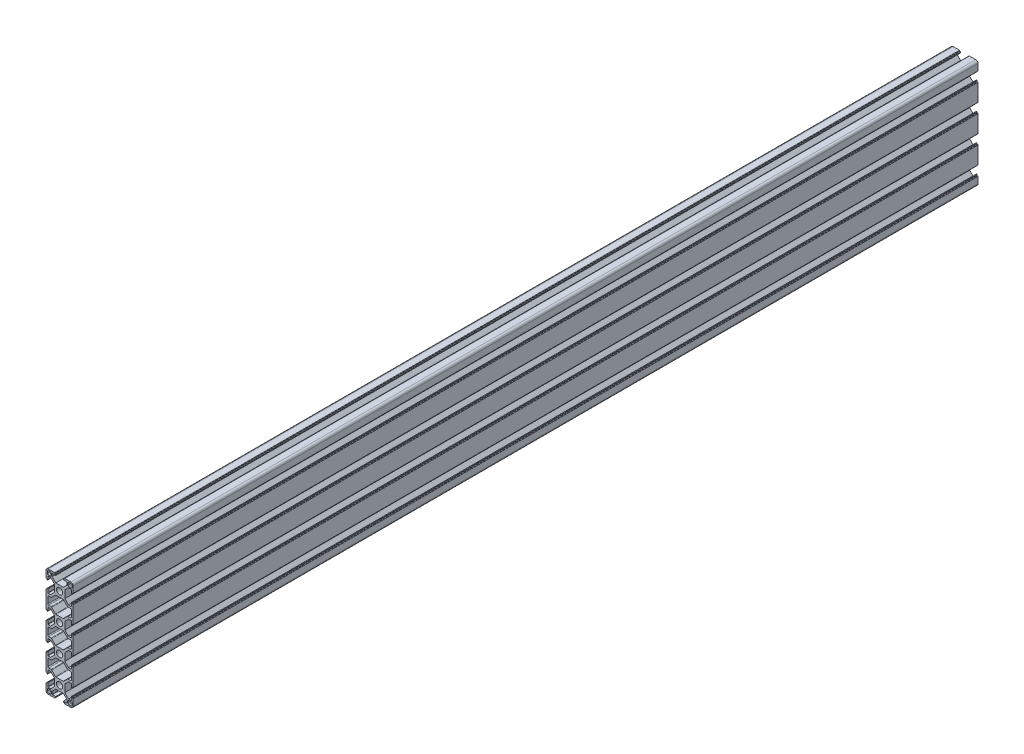
from build123d import *

# Parameters (mm, degrees)
SKETCH_1_R      = 3.4
EXTRUDE_1_DEPTH = 1000


with BuildPart() as part:
    # Эскиз1 → Бобышка-Вытянуть1 (new body)
    with BuildSketch(Plane.XY):
        with BuildLine():
            Line((-15, 8.25), (-15, 12.5))
            ThreePointArc((-15, 12.5), (-14.267766953, 14.267766953), (-12.5, 15))
            Line((-12.5, 15), (-8.25, 15))
            Line((-8.25, 15), (-5.5, 15))
            ThreePointArc((-5.5, 15), (-5.287867966, 14.912132034), (-5.2, 14.7))
            Line((-5.2, 14.7), (-5.2, 14.3))
            ThreePointArc((-5.2, 14.3), (-5.112132034, 14.087867966), (-4.9, 14))
            Line((-4.9, 14), (-4.4, 14))
            ThreePointArc((-4.4, 14), (-4.187867966, 13.912132034), (-4.1, 13.7))
            Line((-4.1, 13.7), (-4.1, 13.3))
            ThreePointArc((-4.1, 13.3), (-4.187867966, 13.087867966), (-4.4, 13))
            Line((-4.4, 13), (-7.95, 13))
            ThreePointArc((-7.95, 13), (-8.162132034, 12.912132034), (-8.25, 12.7))
            Line((-8.25, 12.7), (-8.25, 9.85))
            Line((-8.25, 9.85), (-4.2, 5.8))
            Line((-4.2, 5.8), (4.2, 5.8))
            Line((4.2, 5.8), (8.25, 9.85))
            Line((8.25, 9.85), (8.25, 12.7))
            ThreePointArc((8.25, 12.7), (8.162132034, 12.912132034), (7.95, 13))
            Line((7.95, 13), (4.4, 13))
            ThreePointArc((4.4, 13), (4.187867966, 13.087867966), (4.1, 13.3))
            Line((4.1, 13.3), (4.1, 13.7))
            ThreePointArc((4.1, 13.7), (4.187867966, 13.912132034), (4.4, 14))
            Line((4.4, 14), (4.9, 14))
            ThreePointArc((4.9, 14), (5.112132034, 14.087867966), (5.2, 14.3))
            Line((5.2, 14.3), (5.2, 14.7))
            ThreePointArc((5.2, 14.7), (5.287867966, 14.912132034), (5.5, 15))
            Line((5.5, 15), (8.25, 15))
            Line((8.25, 15), (12.5, 15))
            ThreePointArc((12.5, 15), (14.267766953, 14.267766953), (15, 12.5))
            Line((15, 12.5), (15, 8.25))
            Line((15, 8.25), (15, 5.5))
            ThreePointArc((15, 5.5), (14.912132034, 5.287867966), (14.7, 5.2))
            Line((14.7, 5.2), (14.3, 5.2))
            ThreePointArc((14.3, 5.2), (14.087867966, 5.112132034), (14, 4.9))
            Line((14, 4.9), (14, 4.4))
            ThreePointArc((14, 4.4), (13.912132034, 4.187867966), (13.7, 4.1))
            Line((13.7, 4.1), (13.3, 4.1))
            ThreePointArc((13.3, 4.1), (13.087867966, 4.187867966), (13, 4.4))
            Line((13, 4.4), (13, 7.95))
            ThreePointArc((13, 7.95), (12.912132034, 8.162132034), (12.7, 8.25))
            Line((12.7, 8.25), (9.85, 8.25))
            Line((9.85, 8.25), (5.8, 4.2))
            Line((5.8, 4.2), (5.8, -4.2))
            Line((5.8, -4.2), (9.85, -8.25))
            Line((9.85, -8.25), (12.7, -8.25))
            ThreePointArc((12.7, -8.25), (12.912132034, -8.162132034), (13, -7.95))
            Line((13, -7.95), (13, -4.4))
            ThreePointArc((13, -4.4), (13.087867966, -4.187867966), (13.3, -4.1))
            Line((13.3, -4.1), (13.7, -4.1))
            ThreePointArc((13.7, -4.1), (13.912132034, -4.187867966), (14, -4.4))
            Line((14, -4.4), (14, -4.9))
            ThreePointArc((14, -4.9), (14.087867966, -5.112132034), (14.3, -5.2))
            Line((14.3, -5.2), (14.7, -5.2))
            ThreePointArc((14.7, -5.2), (14.912132034, -5.287867966), (15, -5.5))
            Line((15, -5.5), (15, -8.25))
            Line((15, -8.25), (15, -21.75))
            Line((15, -21.75), (15, -24.5))
            ThreePointArc((15, -24.5), (14.912132034, -24.712132034), (14.7, -24.8))
            Line((14.7, -24.8), (14.3, -24.8))
            ThreePointArc((14.3, -24.8), (14.087867966, -24.887867966), (14, -25.1))
            Line((14, -25.1), (14, -25.6))
            ThreePointArc((14, -25.6), (13.912132034, -25.812132034), (13.7, -25.9))
            Line((13.7, -25.9), (13.3, -25.9))
            ThreePointArc((13.3, -25.9), (13.087867966, -25.812132034), (13, -25.6))
            Line((13, -25.6), (13, -22.05))
            ThreePointArc((13, -22.05), (12.912132034, -21.837867966), (12.7, -21.75))
            Line((12.7, -21.75), (9.85, -21.75))
            Line((9.85, -21.75), (5.8, -25.8))
            Line((5.8, -25.8), (5.8, -34.2))
            Line((5.8, -34.2), (9.85, -38.25))
            Line((9.85, -38.25), (12.7, -38.25))
            ThreePointArc((12.7, -38.25), (12.912132034, -38.162132034), (13, -37.95))
            Line((13, -37.95), (13, -34.4))
            ThreePointArc((13, -34.4), (13.087867966, -34.187867966), (13.3, -34.1))
            Line((13.3, -34.1), (13.7, -34.1))
            ThreePointArc((13.7, -34.1), (13.912132034, -34.187867966), (14, -34.4))
            Line((14, -34.4), (14, -34.9))
            ThreePointArc((14, -34.9), (14.087867966, -35.112132034), (14.3, -35.2))
            Line((14.3, -35.2), (14.7, -35.2))
            ThreePointArc((14.7, -35.2), (14.912132034, -35.287867966), (15, -35.5))
            Line((15, -35.5), (15, -38.25))
            Line((15, -38.25), (15, -51.75))
            Line((15, -51.75), (15, -54.5))
            ThreePointArc((15, -54.5), (14.912132034, -54.712132034), (14.7, -54.8))
            Line((14.7, -54.8), (14.3, -54.8))
            ThreePointArc((14.3, -54.8), (14.087867966, -54.887867966), (14, -55.1))
            Line((14, -55.1), (14, -55.6))
            ThreePointArc((14, -55.6), (13.912132034, -55.812132034), (13.7, -55.9))
            Line((13.7, -55.9), (13.3, -55.9))
            ThreePointArc((13.3, -55.9), (13.087867966, -55.812132034), (13, -55.6))
            Line((13, -55.6), (13, -52.05))
            ThreePointArc((13, -52.05), (12.912132034, -51.837867966), (12.7, -51.75))
            Line((12.7, -51.75), (9.85, -51.75))
            Line((9.85, -51.75), (5.8, -55.8))
            Line((5.8, -55.8), (5.8, -64.2))
            Line((5.8, -64.2), (9.85, -68.25))
            Line((9.85, -68.25), (12.7, -68.25))
            ThreePointArc((12.7, -68.25), (12.912132034, -68.162132034), (13, -67.95))
            Line((13, -67.95), (13, -64.4))
            ThreePointArc((13, -64.4), (13.087867966, -64.187867966), (13.3, -64.1))
            Line((13.3, -64.1), (13.7, -64.1))
            ThreePointArc((13.7, -64.1), (13.912132034, -64.187867966), (14, -64.4))
            Line((14, -64.4), (14, -64.9))
            ThreePointArc((14, -64.9), (14.087867966, -65.112132034), (14.3, -65.2))
            Line((14.3, -65.2), (14.7, -65.2))
            ThreePointArc((14.7, -65.2), (14.912132034, -65.287867966), (15, -65.5))
            Line((15, -65.5), (15, -68.25))
            Line((15, -68.25), (15, -81.75))
            Line((15, -81.75), (15, -84.5))
            ThreePointArc((15, -84.5), (14.912132034, -84.712132034), (14.7, -84.8))
            Line((14.7, -84.8), (14.3, -84.8))
            ThreePointArc((14.3, -84.8), (14.087867966, -84.887867966), (14, -85.1))
            Line((14, -85.1), (14, -85.6))
            ThreePointArc((14, -85.6), (13.912132034, -85.812132034), (13.7, -85.9))
            Line((13.7, -85.9), (13.3, -85.9))
            ThreePointArc((13.3, -85.9), (13.087867966, -85.812132034), (13, -85.6))
            Line((13, -85.6), (13, -82.05))
            ThreePointArc((13, -82.05), (12.912132034, -81.837867966), (12.7, -81.75))
            Line((12.7, -81.75), (9.85, -81.75))
            Line((9.85, -81.75), (5.8, -85.8))
            Line((5.8, -85.8), (5.8, -94.2))
            Line((5.8, -94.2), (9.85, -98.25))
            Line((9.85, -98.25), (12.7, -98.25))
            ThreePointArc((12.7, -98.25), (12.912132034, -98.162132034), (13, -97.95))
            Line((13, -97.95), (13, -94.4))
            ThreePointArc((13, -94.4), (13.087867966, -94.187867966), (13.3, -94.1))
            Line((13.3, -94.1), (13.7, -94.1))
            ThreePointArc((13.7, -94.1), (13.912132034, -94.187867966), (14, -94.4))
            Line((14, -94.4), (14, -94.9))
            ThreePointArc((14, -94.9), (14.087867966, -95.112132034), (14.3, -95.2))
            Line((14.3, -95.2), (14.7, -95.2))
            ThreePointArc((14.7, -95.2), (14.912132034, -95.287867966), (15, -95.5))
            Line((15, -95.5), (15, -98.25))
            Line((15, -98.25), (15, -102.5))
            ThreePointArc((15, -102.5), (14.267766953, -104.267766953), (12.5, -105))
            Line((12.5, -105), (8.25, -105))
            Line((8.25, -105), (5.5, -105))
            ThreePointArc((5.5, -105), (5.287867966, -104.912132034), (5.2, -104.7))
            Line((5.2, -104.7), (5.2, -104.3))
            ThreePointArc((5.2, -104.3), (5.112132034, -104.087867966), (4.9, -104))
            Line((4.9, -104), (4.4, -104))
            ThreePointArc((4.4, -104), (4.187867966, -103.912132034), (4.1, -103.7))
            Line((4.1, -103.7), (4.1, -103.3))
            ThreePointArc((4.1, -103.3), (4.187867966, -103.087867966), (4.4, -103))
            Line((4.4, -103), (7.95, -103))
            ThreePointArc((7.95, -103), (8.162132034, -102.912132034), (8.25, -102.7))
            Line((8.25, -102.7), (8.25, -99.85))
            Line((8.25, -99.85), (4.2, -95.8))
            Line((4.2, -95.8), (-4.2, -95.8))
            Line((-4.2, -95.8), (-8.25, -99.85))
            Line((-8.25, -99.85), (-8.25, -102.7))
            ThreePointArc((-8.25, -102.7), (-8.162132034, -102.912132034), (-7.95, -103))
            Line((-7.95, -103), (-4.4, -103))
            ThreePointArc((-4.4, -103), (-4.187867966, -103.087867966), (-4.1, -103.3))
            Line((-4.1, -103.3), (-4.1, -103.7))
            ThreePointArc((-4.1, -103.7), (-4.187867966, -103.912132034), (-4.4, -104))
            Line((-4.4, -104), (-4.9, -104))
            ThreePointArc((-4.9, -104), (-5.112132034, -104.087867966), (-5.2, -104.3))
            Line((-5.2, -104.3), (-5.2, -104.7))
            ThreePointArc((-5.2, -104.7), (-5.287867966, -104.912132034), (-5.5, -105))
            Line((-5.5, -105), (-8.25, -105))
            Line((-8.25, -105), (-12.5, -105))
            ThreePointArc((-12.5, -105), (-14.267766953, -104.267766953), (-15, -102.5))
            Line((-15, -102.5), (-15, -98.25))
            Line((-15, -98.25), (-15, -95.5))
            ThreePointArc((-15, -95.5), (-14.912132034, -95.287867966), (-14.7, -95.2))
            Line((-14.7, -95.2), (-14.3, -95.2))
            ThreePointArc((-14.3, -95.2), (-14.087867966, -95.112132034), (-14, -94.9))
            Line((-14, -94.9), (-14, -94.4))
            ThreePointArc((-14, -94.4), (-13.912132034, -94.187867966), (-13.7, -94.1))
            Line((-13.7, -94.1), (-13.3, -94.1))
            ThreePointArc((-13.3, -94.1), (-13.087867966, -94.187867966), (-13, -94.4))
            Line((-13, -94.4), (-13, -97.95))
            ThreePointArc((-13, -97.95), (-12.912132034, -98.162132034), (-12.7, -98.25))
            Line((-12.7, -98.25), (-9.85, -98.25))
            Line((-9.85, -98.25), (-5.8, -94.2))
            Line((-5.8, -94.2), (-5.8, -85.8))
            Line((-5.8, -85.8), (-9.85, -81.75))
            Line((-9.85, -81.75), (-12.7, -81.75))
            ThreePointArc((-12.7, -81.75), (-12.912132034, -81.837867966), (-13, -82.05))
            Line((-13, -82.05), (-13, -85.6))
            ThreePointArc((-13, -85.6), (-13.087867966, -85.812132034), (-13.3, -85.9))
            Line((-13.3, -85.9), (-13.7, -85.9))
            ThreePointArc((-13.7, -85.9), (-13.912132034, -85.812132034), (-14, -85.6))
            Line((-14, -85.6), (-14, -85.1))
            ThreePointArc((-14, -85.1), (-14.087867966, -84.887867966), (-14.3, -84.8))
            Line((-14.3, -84.8), (-14.7, -84.8))
            ThreePointArc((-14.7, -84.8), (-14.912132034, -84.712132034), (-15, -84.5))
            Line((-15, -84.5), (-15, -81.75))
            Line((-15, -81.75), (-15, -68.25))
            Line((-15, -68.25), (-15, -65.5))
            ThreePointArc((-15, -65.5), (-14.912132034, -65.287867966), (-14.7, -65.2))
            Line((-14.7, -65.2), (-14.3, -65.2))
            ThreePointArc((-14.3, -65.2), (-14.087867966, -65.112132034), (-14, -64.9))
            Line((-14, -64.9), (-14, -64.4))
            ThreePointArc((-14, -64.4), (-13.912132034, -64.187867966), (-13.7, -64.1))
            Line((-13.7, -64.1), (-13.3, -64.1))
            ThreePointArc((-13.3, -64.1), (-13.087867966, -64.187867966), (-13, -64.4))
            Line((-13, -64.4), (-13, -67.95))
            ThreePointArc((-13, -67.95), (-12.912132034, -68.162132034), (-12.7, -68.25))
            Line((-12.7, -68.25), (-9.85, -68.25))
            Line((-9.85, -68.25), (-5.8, -64.2))
            Line((-5.8, -64.2), (-5.8, -55.8))
            Line((-5.8, -55.8), (-9.85, -51.75))
            Line((-9.85, -51.75), (-12.7, -51.75))
            ThreePointArc((-12.7, -51.75), (-12.912132034, -51.837867966), (-13, -52.05))
            Line((-13, -52.05), (-13, -55.6))
            ThreePointArc((-13, -55.6), (-13.087867966, -55.812132034), (-13.3, -55.9))
            Line((-13.3, -55.9), (-13.7, -55.9))
            ThreePointArc((-13.7, -55.9), (-13.912132034, -55.812132034), (-14, -55.6))
            Line((-14, -55.6), (-14, -55.1))
            ThreePointArc((-14, -55.1), (-14.087867966, -54.887867966), (-14.3, -54.8))
            Line((-14.3, -54.8), (-14.7, -54.8))
            ThreePointArc((-14.7, -54.8), (-14.912132034, -54.712132034), (-15, -54.5))
            Line((-15, -54.5), (-15, -51.75))
            Line((-15, -51.75), (-15, -38.25))
            Line((-15, -38.25), (-15, -35.5))
            ThreePointArc((-15, -35.5), (-14.912132034, -35.287867966), (-14.7, -35.2))
            Line((-14.7, -35.2), (-14.3, -35.2))
            ThreePointArc((-14.3, -35.2), (-14.087867966, -35.112132034), (-14, -34.9))
            Line((-14, -34.9), (-14, -34.4))
            ThreePointArc((-14, -34.4), (-13.912132034, -34.187867966), (-13.7, -34.1))
            Line((-13.7, -34.1), (-13.3, -34.1))
            ThreePointArc((-13.3, -34.1), (-13.087867966, -34.187867966), (-13, -34.4))
            Line((-13, -34.4), (-13, -37.95))
            ThreePointArc((-13, -37.95), (-12.912132034, -38.162132034), (-12.7, -38.25))
            Line((-12.7, -38.25), (-9.85, -38.25))
            Line((-9.85, -38.25), (-5.8, -34.2))
            Line((-5.8, -34.2), (-5.8, -25.8))
            Line((-5.8, -25.8), (-9.85, -21.75))
            Line((-9.85, -21.75), (-12.7, -21.75))
            ThreePointArc((-12.7, -21.75), (-12.912132034, -21.837867966), (-13, -22.05))
            Line((-13, -22.05), (-13, -25.6))
            ThreePointArc((-13, -25.6), (-13.087867966, -25.812132034), (-13.3, -25.9))
            Line((-13.3, -25.9), (-13.7, -25.9))
            ThreePointArc((-13.7, -25.9), (-13.912132034, -25.812132034), (-14, -25.6))
            Line((-14, -25.6), (-14, -25.1))
            ThreePointArc((-14, -25.1), (-14.087867966, -24.887867966), (-14.3, -24.8))
            Line((-14.3, -24.8), (-14.7, -24.8))
            ThreePointArc((-14.7, -24.8), (-14.912132034, -24.712132034), (-15, -24.5))
            Line((-15, -24.5), (-15, -21.75))
            Line((-15, -21.75), (-15, -8.25))
            Line((-15, -8.25), (-15, -5.5))
            ThreePointArc((-15, -5.5), (-14.912132034, -5.287867966), (-14.7, -5.2))
            Line((-14.7, -5.2), (-14.3, -5.2))
            ThreePointArc((-14.3, -5.2), (-14.087867966, -5.112132034), (-14, -4.9))
            Line((-14, -4.9), (-14, -4.4))
            ThreePointArc((-14, -4.4), (-13.912132034, -4.187867966), (-13.7, -4.1))
            Line((-13.7, -4.1), (-13.3, -4.1))
            ThreePointArc((-13.3, -4.1), (-13.087867966, -4.187867966), (-13, -4.4))
            Line((-13, -4.4), (-13, -7.95))
            ThreePointArc((-13, -7.95), (-12.912132034, -8.162132034), (-12.7, -8.25))
            Line((-12.7, -8.25), (-9.85, -8.25))
            Line((-9.85, -8.25), (-5.8, -4.2))
            Line((-5.8, -4.2), (-5.8, 4.2))
            Line((-5.8, 4.2), (-9.85, 8.25))
            Line((-9.85, 8.25), (-12.7, 8.25))
            ThreePointArc((-12.7, 8.25), (-12.912132034, 8.162132034), (-13, 7.95))
            Line((-13, 7.95), (-13, 4.4))
            ThreePointArc((-13, 4.4), (-13.087867966, 4.187867966), (-13.3, 4.1))
            Line((-13.3, 4.1), (-13.7, 4.1))
            ThreePointArc((-13.7, 4.1), (-13.912132034, 4.187867966), (-14, 4.4))
            Line((-14, 4.4), (-14, 4.9))
            ThreePointArc((-14, 4.9), (-14.087867966, 5.112132034), (-14.3, 5.2))
            Line((-14.3, 5.2), (-14.7, 5.2))
            ThreePointArc((-14.7, 5.2), (-14.912132034, 5.287867966), (-15, 5.5))
            Line((-15, 5.5), (-15, 8.25))
        make_face()
        Circle(SKETCH_1_R, mode=Mode.SUBTRACT)
        with Locations((0, -30)):
            Circle(SKETCH_1_R, mode=Mode.SUBTRACT)
        with Locations((0, -60)):
            Circle(SKETCH_1_R, mode=Mode.SUBTRACT)
        with Locations((0, -90)):
            Circle(SKETCH_1_R, mode=Mode.SUBTRACT)
        with BuildLine():
            Line((12.55, 9.35), (10.35, 9.35))
            ThreePointArc((10.35, 9.35), (9.642893219, 9.642893219), (9.35, 10.35))
            Line((9.35, 10.35), (9.35, 12.55))
            ThreePointArc((9.35, 12.55), (9.642893219, 13.257106781), (10.35, 13.55))
            Line((10.35, 13.55), (12.55, 13.55))
            ThreePointArc((12.55, 13.55), (13.257106781, 13.257106781), (13.55, 12.55))
            Line((13.55, 12.55), (13.55, 10.35))
            ThreePointArc((13.55, 10.35), (13.257106781, 9.642893219), (12.55, 9.35))
        make_face(mode=Mode.SUBTRACT)
        with BuildLine():
            Line((-12.55, 13.55), (-10.35, 13.55))
            ThreePointArc((-10.35, 13.55), (-9.642893219, 13.257106781), (-9.35, 12.55))
            Line((-9.35, 12.55), (-9.35, 10.35))
            ThreePointArc((-9.35, 10.35), (-9.642893219, 9.642893219), (-10.35, 9.35))
            Line((-10.35, 9.35), (-12.55, 9.35))
            ThreePointArc((-12.55, 9.35), (-13.257106781, 9.642893219), (-13.55, 10.35))
            Line((-13.55, 10.35), (-13.55, 12.55))
            ThreePointArc((-13.55, 12.55), (-13.257106781, 13.257106781), (-12.55, 13.55))
        make_face(mode=Mode.SUBTRACT)
        with BuildLine():
            Line((-13, -18.5), (-13, -11.5))
            ThreePointArc((-13, -11.5), (-12.707106781, -10.792893219), (-12, -10.5))
            Line((-12, -10.5), (-9.402943725, -10.5))
            ThreePointArc((-9.402943725, -10.5), (-9.020260293, -10.423879533), (-8.695836944, -10.207106781))
            Line((-8.695836944, -10.207106781), (-4.581623382, -6.092893219))
            ThreePointArc((-4.581623382, -6.092893219), (-4.257200033, -5.876120467), (-3.8745166, -5.8))
            Line((-3.8745166, -5.8), (3.8745166, -5.8))
            ThreePointArc((3.8745166, -5.8), (4.257200033, -5.876120467), (4.581623382, -6.092893219))
            Line((4.581623382, -6.092893219), (8.695836944, -10.207106781))
            ThreePointArc((8.695836944, -10.207106781), (9.020260293, -10.423879533), (9.402943725, -10.5))
            Line((9.402943725, -10.5), (12, -10.5))
            ThreePointArc((12, -10.5), (12.707106781, -10.792893219), (13, -11.5))
            Line((13, -11.5), (13, -18.5))
            ThreePointArc((13, -18.5), (12.707106781, -19.207106781), (12, -19.5))
            Line((12, -19.5), (9.402943725, -19.5))
            ThreePointArc((9.402943725, -19.5), (9.020260293, -19.576120467), (8.695836944, -19.792893219))
            Line((8.695836944, -19.792893219), (4.581623382, -23.907106781))
            ThreePointArc((4.581623382, -23.907106781), (4.257200033, -24.123879533), (3.8745166, -24.2))
            Line((3.8745166, -24.2), (-3.8745166, -24.2))
            ThreePointArc((-3.8745166, -24.2), (-4.257200033, -24.123879533), (-4.581623382, -23.907106781))
            Line((-4.581623382, -23.907106781), (-8.695836944, -19.792893219))
            ThreePointArc((-8.695836944, -19.792893219), (-9.020260293, -19.576120467), (-9.402943725, -19.5))
            Line((-9.402943725, -19.5), (-12, -19.5))
            ThreePointArc((-12, -19.5), (-12.707106781, -19.207106781), (-13, -18.5))
        make_face(mode=Mode.SUBTRACT)
        with BuildLine():
            Line((-12, -70.5), (-9.402943725, -70.5))
            ThreePointArc((-9.402943725, -70.5), (-9.020260293, -70.423879533), (-8.695836944, -70.207106781))
            Line((-8.695836944, -70.207106781), (-4.581623382, -66.092893219))
            ThreePointArc((-4.581623382, -66.092893219), (-4.257200033, -65.876120467), (-3.8745166, -65.8))
            Line((-3.8745166, -65.8), (3.8745166, -65.8))
            ThreePointArc((3.8745166, -65.8), (4.257200033, -65.876120467), (4.581623382, -66.092893219))
            Line((4.581623382, -66.092893219), (8.695836944, -70.207106781))
            ThreePointArc((8.695836944, -70.207106781), (9.020260293, -70.423879533), (9.402943725, -70.5))
            Line((9.402943725, -70.5), (12, -70.5))
            ThreePointArc((12, -70.5), (12.707106781, -70.792893219), (13, -71.5))
            Line((13, -71.5), (13, -78.5))
            ThreePointArc((13, -78.5), (12.707106781, -79.207106781), (12, -79.5))
            Line((12, -79.5), (9.402943725, -79.5))
            ThreePointArc((9.402943725, -79.5), (9.020260293, -79.576120467), (8.695836944, -79.792893219))
            Line((8.695836944, -79.792893219), (4.581623382, -83.907106781))
            ThreePointArc((4.581623382, -83.907106781), (4.257200033, -84.123879533), (3.8745166, -84.2))
            Line((3.8745166, -84.2), (-3.8745166, -84.2))
            ThreePointArc((-3.8745166, -84.2), (-4.257200033, -84.123879533), (-4.581623382, -83.907106781))
            Line((-4.581623382, -83.907106781), (-8.695836944, -79.792893219))
            ThreePointArc((-8.695836944, -79.792893219), (-9.020260293, -79.576120467), (-9.402943725, -79.5))
            Line((-9.402943725, -79.5), (-12, -79.5))
            ThreePointArc((-12, -79.5), (-12.707106781, -79.207106781), (-13, -78.5))
            Line((-13, -78.5), (-13, -71.5))
            ThreePointArc((-13, -71.5), (-12.707106781, -70.792893219), (-12, -70.5))
        make_face(mode=Mode.SUBTRACT)
        with BuildLine():
            Line((9.35, -102.55), (9.35, -100.35))
            ThreePointArc((9.35, -100.35), (9.642893219, -99.642893219), (10.35, -99.35))
            Line((10.35, -99.35), (12.55, -99.35))
            ThreePointArc((12.55, -99.35), (13.257106781, -99.642893219), (13.55, -100.35))
            Line((13.55, -100.35), (13.55, -102.55))
            ThreePointArc((13.55, -102.55), (13.257106781, -103.257106781), (12.55, -103.55))
            Line((12.55, -103.55), (10.35, -103.55))
            ThreePointArc((10.35, -103.55), (9.642893219, -103.257106781), (9.35, -102.55))
        make_face(mode=Mode.SUBTRACT)
        with BuildLine():
            Line((-9.35, -102.55), (-9.35, -100.35))
            ThreePointArc((-9.35, -100.35), (-9.642893219, -99.642893219), (-10.35, -99.35))
            Line((-10.35, -99.35), (-12.55, -99.35))
            ThreePointArc((-12.55, -99.35), (-13.257106781, -99.642893219), (-13.55, -100.35))
            Line((-13.55, -100.35), (-13.55, -102.55))
            ThreePointArc((-13.55, -102.55), (-13.257106781, -103.257106781), (-12.55, -103.55))
            Line((-12.55, -103.55), (-10.35, -103.55))
            ThreePointArc((-10.35, -103.55), (-9.642893219, -103.257106781), (-9.35, -102.55))
        make_face(mode=Mode.SUBTRACT)
        with BuildLine():
            Line((12, -40.5), (9.402943725, -40.5))
            ThreePointArc((9.402943725, -40.5), (9.020260293, -40.423879533), (8.695836944, -40.207106781))
            Line((8.695836944, -40.207106781), (4.581623382, -36.092893219))
            ThreePointArc((4.581623382, -36.092893219), (4.257200033, -35.876120467), (3.8745166, -35.8))
            Line((3.8745166, -35.8), (-3.8745166, -35.8))
            ThreePointArc((-3.8745166, -35.8), (-4.257200033, -35.876120467), (-4.581623382, -36.092893219))
            Line((-4.581623382, -36.092893219), (-8.695836944, -40.207106781))
            ThreePointArc((-8.695836944, -40.207106781), (-9.020260293, -40.423879533), (-9.402943725, -40.5))
            Line((-9.402943725, -40.5), (-12, -40.5))
            ThreePointArc((-12, -40.5), (-12.707106781, -40.792893219), (-13, -41.5))
            Line((-13, -41.5), (-13, -48.5))
            ThreePointArc((-13, -48.5), (-12.707106781, -49.207106781), (-12, -49.5))
            Line((-12, -49.5), (-9.402943725, -49.5))
            ThreePointArc((-9.402943725, -49.5), (-9.020260293, -49.576120467), (-8.695836944, -49.792893219))
            Line((-8.695836944, -49.792893219), (-4.581623382, -53.907106781))
            ThreePointArc((-4.581623382, -53.907106781), (-4.257200033, -54.123879533), (-3.8745166, -54.2))
            Line((-3.8745166, -54.2), (3.8745166, -54.2))
            ThreePointArc((3.8745166, -54.2), (4.257200033, -54.123879533), (4.581623382, -53.907106781))
            Line((4.581623382, -53.907106781), (8.695836944, -49.792893219))
            ThreePointArc((8.695836944, -49.792893219), (9.020260293, -49.576120467), (9.402943725, -49.5))
            Line((9.402943725, -49.5), (12, -49.5))
            ThreePointArc((12, -49.5), (12.707106781, -49.207106781), (13, -48.5))
            Line((13, -48.5), (13, -41.5))
            ThreePointArc((13, -41.5), (12.707106781, -40.792893219), (12, -40.5))
        make_face(mode=Mode.SUBTRACT)
    extrude(amount=EXTRUDE_1_DEPTH)


solid = part.part
